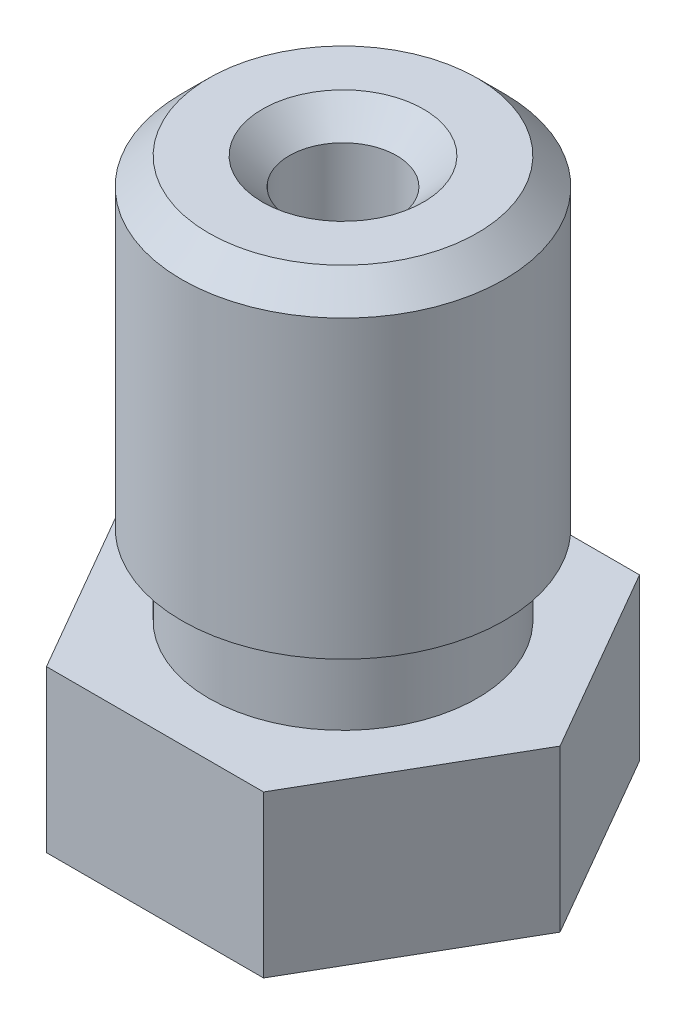
from build123d import *

# Parameters (mm, degrees)
BOSS_EXTRUDE1_DEPTH = 3
CHAMFER1_SIZE       = 0.5


with BuildPart() as part:
    # Sketch1 → Boss-Extrude1 (new body)
    with BuildSketch(Plane.XZ):
        Polygon((-2.020725942, 3.5), (-4.041451884, 0), (-2.020725942, -3.5), (2.020725942, -3.5), (4.041451884, 0), (2.020725942, 3.5), align=None)
    extrude(amount=-BOSS_EXTRUDE1_DEPTH)

    # Sketch2 → Revolve1 (revolve)
    with BuildSketch(Plane(origin=(0, 0, 0), x_dir=(-1, 0, 0), z_dir=(0, 0, -1))):
        Polygon((-2.5, 3), (0, 3), (0, 10.5), (-3, 10.5), (-3, 4.5), (-2.5, 4.5), align=None)
    revolve(axis=Axis((0, 3, 0), (0, 1, 0)))

    # Sketch3 → Revolve2 (revolve)
    with BuildSketch(Plane.XY):
        Polygon((2.5, 0), (0, 0), (0, -2), (0.5, -2), align=None)
    revolve(axis=Axis((0, 0, 0), (0, -1, 0)))

    # Sketch4 → Cut-Revolve1 (revolve, cut)
    with BuildSketch(Plane(origin=(0, 0, 0), x_dir=(-1, 0, 0), z_dir=(0, 0, -1))):
        Polygon((-0.15, -2), (0, -2), (0, 10.5), (-1, 10.5), (-1, 0), (-0.75, -0.227272727), (-0.75, -0.7), (-0.15, -1.2), align=None)
    revolve(axis=Axis((0, -2, 0), (0, 1, 0)), mode=Mode.SUBTRACT)

    # Chamfer1
    chamfer1_edges = [part.edges().sort_by_distance(p)[0] for p in [
        (-3, 10.5, 0),
        (-1, 10.5, 0),
    ]]
    chamfer(chamfer1_edges, length=CHAMFER1_SIZE)


solid = part.part
